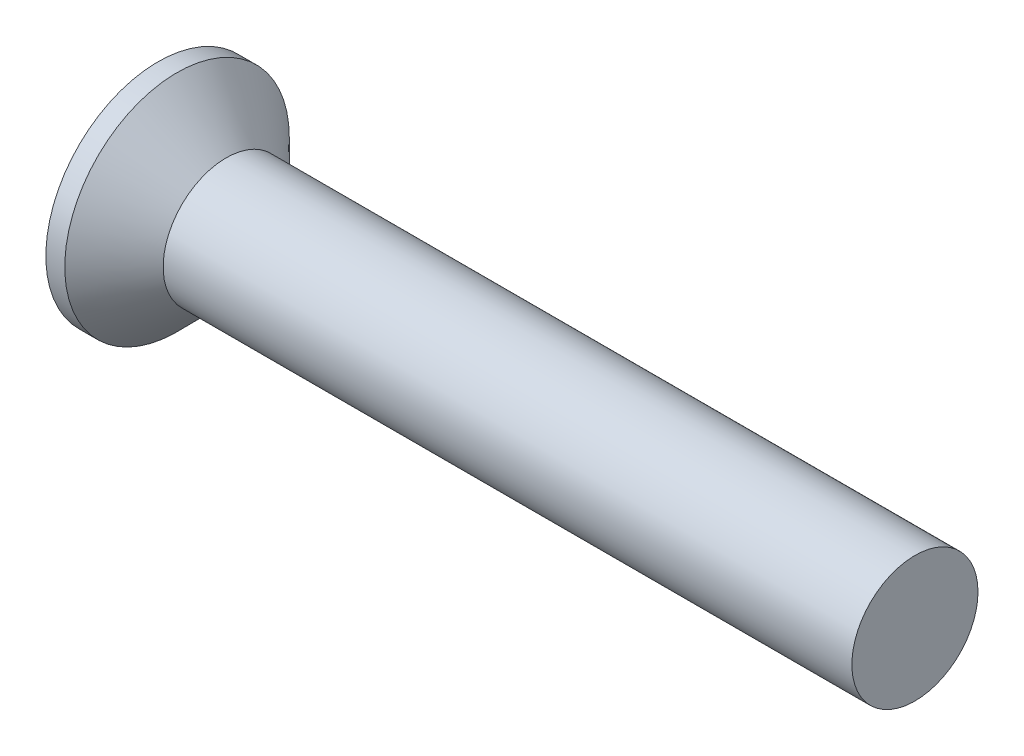
from build123d import *

# Parameters (mm, degrees)
CROSSRECESS_DEPTH = 1.35
DRAFT9_ANGLE      = 30
FILLET5_R         = 0.3
SKETCH10_W        = 0.8
SKETCH10_H        = 2.5


with BuildPart() as part:
    # Sketch1 → Base (revolve)
    with BuildSketch(Plane.XY):
        Polygon((30, 2.5), (4.3, 2.5), (2.7, 2.5), (0.75, 4.45), (0, 4.45), (0, 0), (30, 0), align=None)
    revolve(axis=Axis((4.515812911, 0, 0), (-1, 0, 0)))

    # Sketch6 → CrossRecess (cut)
    with BuildSketch(Plane(origin=(0, 0, 0), x_dir=(0, 0, -1), z_dir=(1, 0, 0))):
        Polygon((0.52, 0.52), (0.52, 2.6), (-0.52, 2.6), (-0.52, 0.52), (-2.6, 0.52), (-2.6, -0.52), (-0.52, -0.52), (-0.52, -2.6), (0.52, -2.6), (0.52, -0.52), (2.6, -0.52), (2.6, 0.52), align=None)
    extrude(amount=CROSSRECESS_DEPTH, mode=Mode.SUBTRACT)

    # Draft9
    draft9_faces = [part.faces().sort_by_distance(p)[0] for p in [
        (0.675, -2.6, 0),
        (0.675, 0, 2.6),
        (0.675, 0, -2.6),
        (0.675, 2.6, 0),
    ]]
    draft(draft9_faces, Plane(origin=(0, 4.45, 0), x_dir=(0, 0, -1), z_dir=(-1, 0, 0)), DRAFT9_ANGLE)

    # Fillet5
    fillet5_edges = [part.edges().sort_by_distance(p)[0] for p in [
        (0.675, 0.52, 0.52),
        (0.675, -0.52, 0.52),
        (0.675, -0.52, -0.52),
        (0.675, 0.52, -0.52),
    ]]
    fillet(fillet5_edges, radius=FILLET5_R)

    # Sketch10 → Revolve2 (revolve)
    with BuildSketch(Plane.XY):
        with Locations((3.1, 1.25)):
            Rectangle(SKETCH10_W, SKETCH10_H)
    revolve(axis=Axis((62.228915663, 0, 0), (-1, 0, 0)))


solid = part.part
